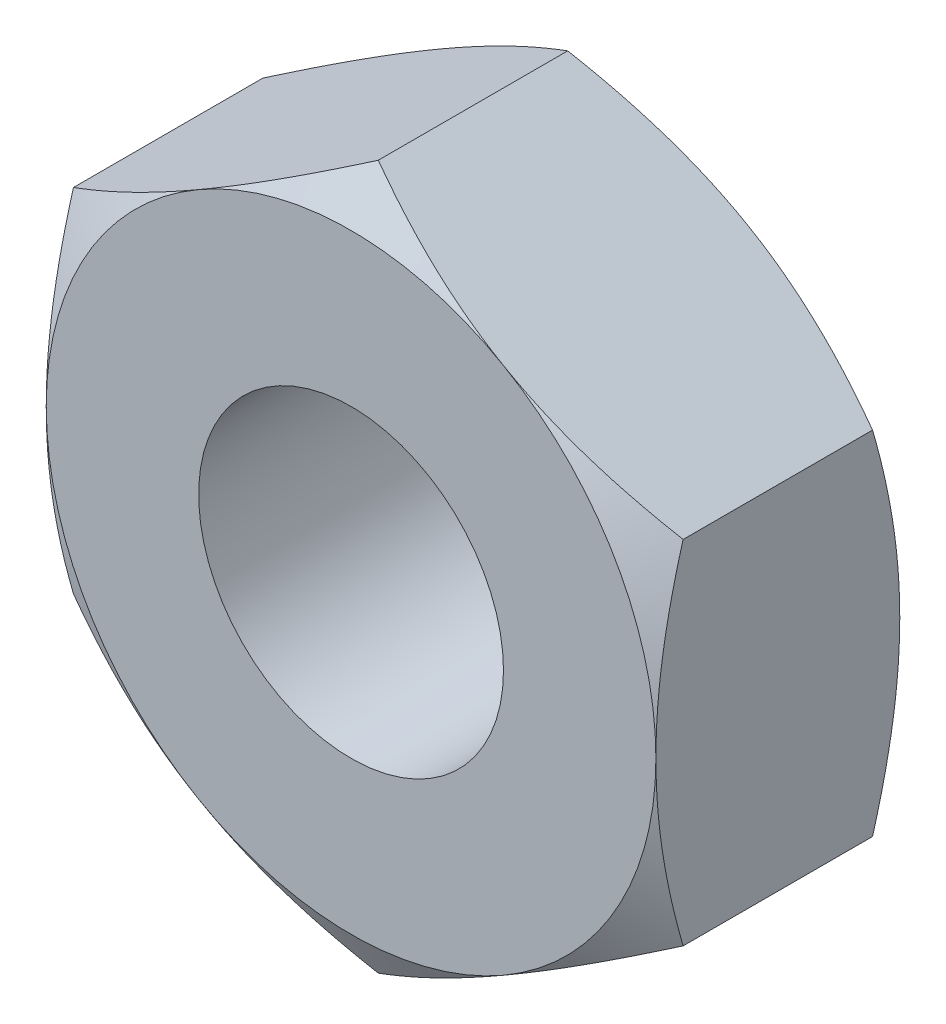
from build123d import *

# Parameters (mm, degrees)
SKETCH2_R                = 1.25
BOSS_EXTRUDE1_DEPTH      = 1
BOSS_EXTRUDE1_DEPTH_BACK = 1
SKETCH3_OUTSIDE_W        = 18.972
SKETCH3_OUTSIDE_H        = 19.746
SKETCH3_OUTSIDE_R        = 2.5
CUT_EXTRUDE1_DEPTH       = 3
CUT_EXTRUDE1_TAPER       = 60


with BuildPart() as part:
    # Sketch2 → Boss-Extrude1 (new body, two sides)
    with BuildSketch(Plane.XY) as boss_extrude1_sk:
        Polygon((0, 2.886751346), (-2.5, 1.443375673), (-2.5, -1.443375673), (0, -2.886751346), (2.5, -1.443375673), (2.5, 1.443375673), align=None)
        Circle(SKETCH2_R, mode=Mode.SUBTRACT)
    extrude(amount=BOSS_EXTRUDE1_DEPTH)
    extrude(boss_extrude1_sk.sketch, amount=-BOSS_EXTRUDE1_DEPTH_BACK)

    # Sketch3 outside → Cut-Extrude1 (cut, through all)
    with BuildSketch(Plane.XY.offset(1)):
        Rectangle(SKETCH3_OUTSIDE_W, SKETCH3_OUTSIDE_H)
        Circle(SKETCH3_OUTSIDE_R, mode=Mode.SUBTRACT)
    cut_extrude1 = extrude(amount=-CUT_EXTRUDE1_DEPTH, taper=CUT_EXTRUDE1_TAPER, mode=Mode.SUBTRACT)

    # Mirror1: Cut-Extrude1 across plane
    add(cut_extrude1.mirror(Plane.XY), mode=Mode.SUBTRACT)


solid = part.part
